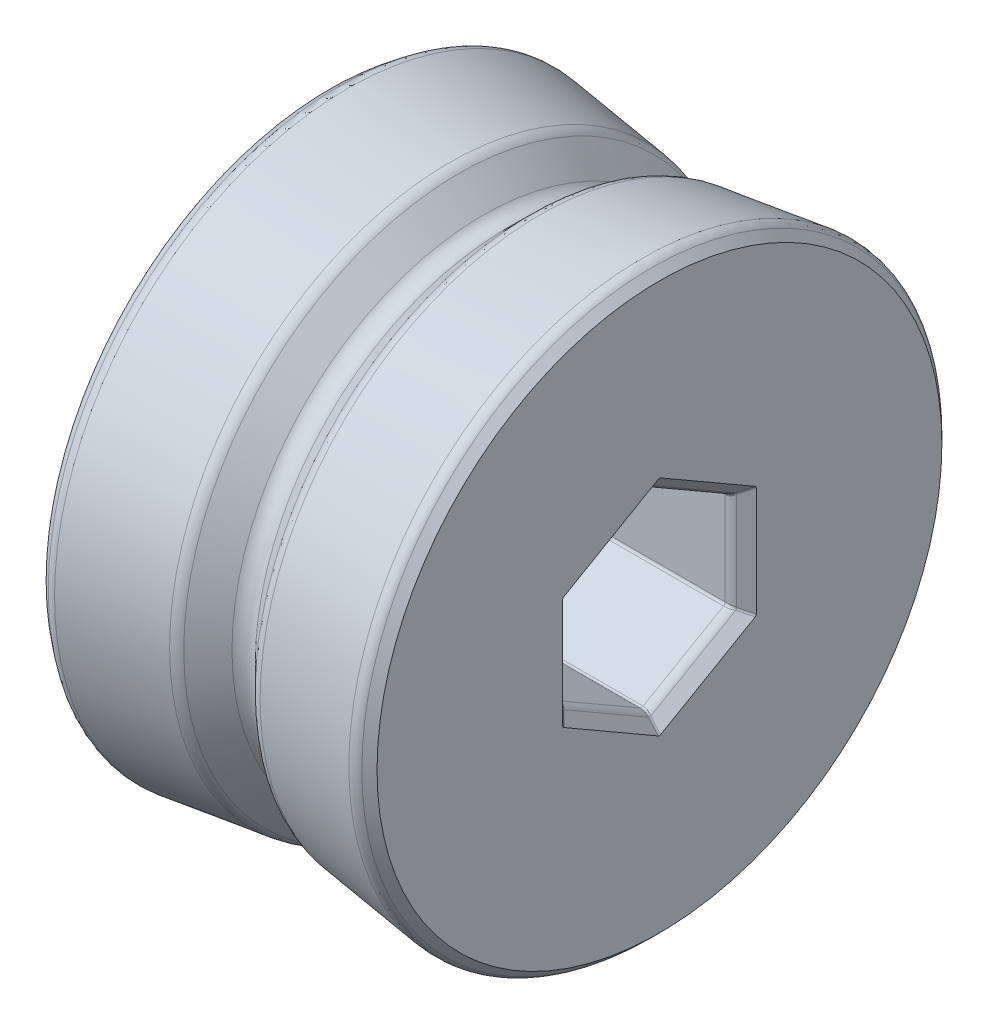
from build123d import *
from OCP.BRepFilletAPI import BRepFilletAPI_MakeChamfer

# Parameters (mm, degrees)
CUT_EXTRUDE1_DEPTH      = 42.033090463
CUT_EXTRUDE1_DEPTH_BACK = 42.033090463
CHAMFER1_SIZE           = 1.016
CHAMFER1_SIZE2          = 0.905549209
FILLET2_R               = 0.889
FILLET3_R               = 0.254


with BuildPart() as part:
    # Sketch1 → Revolve1 (revolve)
    with BuildSketch(Plane.XY, mode=Mode.PRIVATE) as revolve1_sk:
        with BuildLine():
            Line((0, 0), (0, 22.787655792))
            Line((0, 22.787655792), (9.211751557, 21.574905692))
            ThreePointArc((9.211751557, 21.574905692), (9.607689929, 21.4547991), (9.944008905, 21.21379633))
            Line((9.944008905, 21.21379633), (11.801974388, 19.355830847))
            ThreePointArc((11.801974388, 19.355830847), (12.7, 18.983856459), (13.598025612, 19.355830847))
            Line((13.598025612, 19.355830847), (15.455991095, 21.21379633))
            ThreePointArc((15.455991095, 21.21379633), (15.792310071, 21.4547991), (16.188248443, 21.574905692))
            Line((16.188248443, 21.574905692), (25.4, 22.787655792))
            Line((25.4, 22.787655792), (25.4, 0))
            Line((25.4, 0), (0, 0))
        make_face()
    revolve(revolve1_sk.sketch.rotate(Axis((0, 0, 0), (1, 0, 0)), 90), axis=Axis((0, 0, 0), (1, 0, 0)))

    # Sketch2 → Cut-Extrude1 (cut, two sides)
    with BuildSketch(Plane(origin=(25.4, 0, 0), x_dir=(0, 0, -1), z_dir=(1, 0, 0))) as cut_extrude1_sk:
        Polygon((6.45, -3.723909236), (6.45, 3.723909236), (0, 7.447818473), (-6.45, 3.723909236), (-6.45, -3.723909236), (0, -7.447818473), align=None)
    extrude(amount=CUT_EXTRUDE1_DEPTH, mode=Mode.SUBTRACT)
    extrude(cut_extrude1_sk.sketch, amount=-CUT_EXTRUDE1_DEPTH_BACK, mode=Mode.SUBTRACT)

    # Chamfer1: one chamfer whose edges measure the first distance from different faces: ONE call of the kernel's chamfer builder (chamfer() names one face for all edges)
    chamfer1_edges_1 = [part.edges().sort_by_distance(p)[0] for p in [
        (0, 0, -22.787655792),
    ]]
    chamfer1_side_1 = [part.faces().sort_by_distance(p)[0] for p in [
        (4.605875778, 0, -22.181280742),
    ]]
    chamfer1_edges_2 = [part.edges().sort_by_distance(p)[0] for p in [
        (25.4, 0, -6.45),
        (25.4, 5.585863854, -3.225),
        (25.4, 5.585863854, 3.225),
        (25.4, 0, 6.45),
        (25.4, -5.585863854, 3.225),
        (25.4, -5.585863854, -3.225),
        (0, -5.585863854, -3.225),
        (0, -5.585863854, 3.225),
        (0, 0, 6.45),
        (0, 5.585863854, 3.225),
        (0, 5.585863854, -3.225),
        (0, 0, -6.45),
    ]]
    chamfer1_edges_3 = [part.edges().sort_by_distance(p)[0] for p in [
        (25.4, 0, -22.787655792),
    ]]
    chamfer1_side_3 = [part.faces().sort_by_distance(p)[0] for p in [
        (25.4, 0, -22.143123554),
    ]]
    chamfer1 = BRepFilletAPI_MakeChamfer(part.part.solid().wrapped)
    for e in chamfer1_edges_1:
        chamfer1.Add(CHAMFER1_SIZE, CHAMFER1_SIZE2, e.wrapped, chamfer1_side_1[0].wrapped)  # the first distance lies on this face
    for e in chamfer1_edges_2:
        chamfer1.Add(CHAMFER1_SIZE, e.wrapped)
    for e in chamfer1_edges_3:
        chamfer1.Add(CHAMFER1_SIZE, CHAMFER1_SIZE2, e.wrapped, chamfer1_side_3[0].wrapped)  # the first distance lies on this face
    add(Compound.cast(chamfer1.Shape()), mode=Mode.REPLACE)

    # Fillet2
    fillet2_edges = [part.edges().sort_by_distance(p)[0] for p in [
        (1.007307979, 0, -22.65504118),
        (24.384, 0, 6.45),
        (1.016, 0, 6.45),
        (24.384, 5.585863854, 3.225),
        (1.016, 5.585863854, 3.225),
        (24.384, 5.585863854, -3.225),
        (1.016, 5.585863854, -3.225),
        (24.384, 0, -6.45),
        (1.016, 0, -6.45),
        (24.384, -5.585863854, -3.225),
        (1.016, -5.585863854, -3.225),
        (24.384, -5.585863854, 3.225),
        (1.016, -5.585863854, 3.225),
        (24.50219789, 0, -22.669457902),
    ]]
    fillet(fillet2_edges, radius=FILLET2_R)

    # Fillet3
    fillet3_edges = [part.edges().sort_by_distance(p)[0] for p in [
        (12.7, -3.723909236, -6.45),
        (12.7, -7.447818473, 0),
        (0.377808964, -4.092369003, -7.088191036),
        (0.377808964, -8.184738005, 0),
        (12.7, 3.723909236, -6.45),
        (12.7, 7.447818473, 0),
        (12.7, 3.723909236, 6.45),
        (12.7, -3.723909236, 6.45),
        (0.377808964, -4.092369003, 7.088191036),
        (25.022191036, -8.184738005, 0),
        (25.022191036, 4.092369003, -7.088191036),
        (25.022191036, -4.092369003, -7.088191036),
        (1.037339071, 7.52919568, 0),
        (1.037339071, 3.76459784, 6.520474729),
        (1.037339071, 3.76459784, -6.520474729),
        (1.037339071, -3.76459784, 6.520474729),
        (1.037339071, -3.76459784, -6.520474729),
        (1.037339071, -7.52919568, 0),
        (24.362660929, 7.52919568, 0),
        (24.362660929, 3.76459784, -6.520474729),
        (24.362660929, 3.76459784, 6.520474729),
        (24.362660929, -3.76459784, -6.520474729),
        (24.362660929, -3.76459784, 6.520474729),
        (24.362660929, -7.52919568, 0),
        (0.377808964, 4.092369003, -7.088191036),
        (0.377808964, 8.184738005, 0),
        (0.377808964, 4.092369003, 7.088191036),
        (25.022191036, -4.092369003, 7.088191036),
        (25.022191036, 4.092369003, 7.088191036),
        (25.022191036, 8.184738005, 0),
    ]]
    fillet(fillet3_edges, radius=FILLET3_R)


solid = part.part
